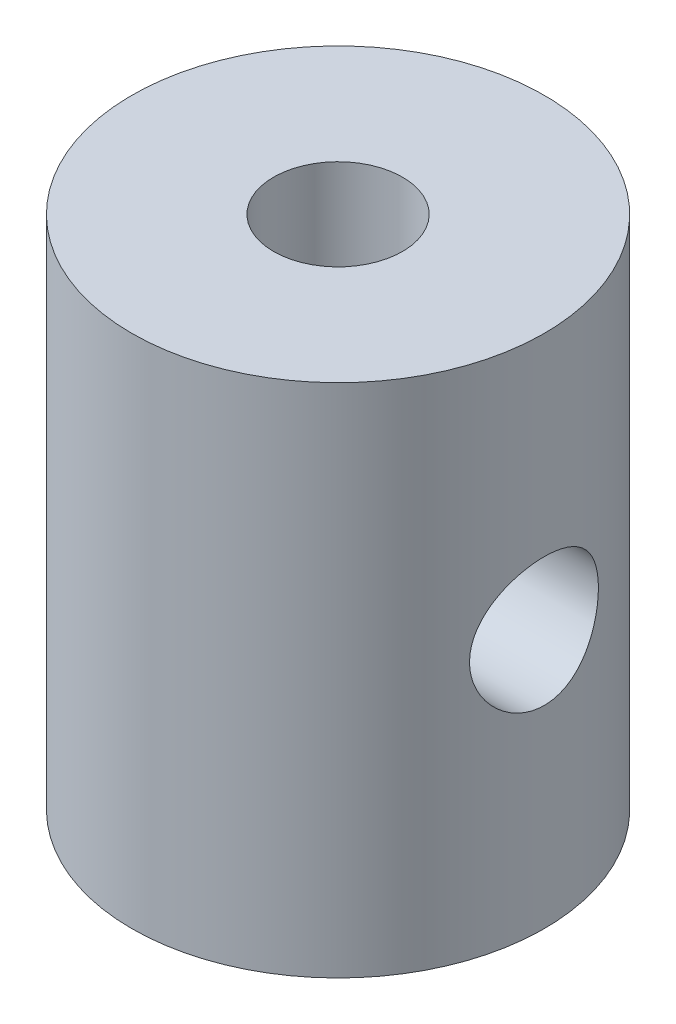
from build123d import *

# Parameters (mm, degrees)
BOSS_EXTRUDE1_DEPTH      = 25
BOSS_EXTRUDE1_DEPTH_BACK = 25
SKETCH2_R                = 20
CUT_EXTRUDE1_DEPTH       = 40
CUT_EXTRUDE1_DEPTH_BACK  = 40
SKETCH3_R                = 6.25
SKETCH4_R                = 6.25
CUT_EXTRUDE2_DEPTH       = 12.5


with BuildPart() as part:
    # Sketch2 → Boss-Extrude1 (new, two sides: drawn at the far end of the back side and taken through both)
    with BuildSketch(Plane(origin=(0, 0, 0), x_dir=(1, 0, 0), z_dir=(0, 1, 0)).offset(-BOSS_EXTRUDE1_DEPTH_BACK)):
        Circle(SKETCH2_R)
    extrude(amount=BOSS_EXTRUDE1_DEPTH + BOSS_EXTRUDE1_DEPTH_BACK)

    # Sketch3 → Cut-Extrude1 (cut, two sides: drawn at the far end of the back side and taken through both)
    with BuildSketch(Plane(origin=(0, 0, 0), x_dir=(0, 0, -1), z_dir=(1, 0, 0)).offset(-CUT_EXTRUDE1_DEPTH_BACK)):
        Circle(SKETCH3_R)
    extrude(amount=CUT_EXTRUDE1_DEPTH + CUT_EXTRUDE1_DEPTH_BACK, mode=Mode.SUBTRACT)

    # Sketch4 → Cut-Extrude2 (cut)
    with BuildSketch(Plane(origin=(0, 25, 0), x_dir=(1, 0, 0), z_dir=(0, 1, 0))):
        Circle(SKETCH4_R)
    cut_extrude2 = extrude(amount=-CUT_EXTRUDE2_DEPTH, mode=Mode.SUBTRACT)

    # Mirror1: Cut-Extrude2 across plane
    add(cut_extrude2.mirror(Plane.ZX), mode=Mode.SUBTRACT)


solid = part.part
